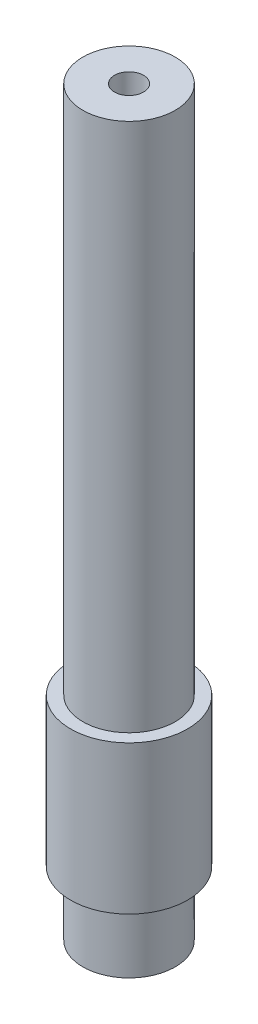
from build123d import *


with BuildPart() as part:
    # Szkic1 → Obrót2 (revolve)
    with BuildSketch(Plane.XY):
        Polygon((-6.35, 0), (-2, 0), (-2, 102), (-6.35, 102), (-6.35, 29.194600335), (-8.05, 29.194600335), (-8.05, 8.805399665), (-6.35, 8.805399665), align=None)
    revolve(axis=Axis((0, -1.093536861, 0), (0, 1, 0)))


solid = part.part
